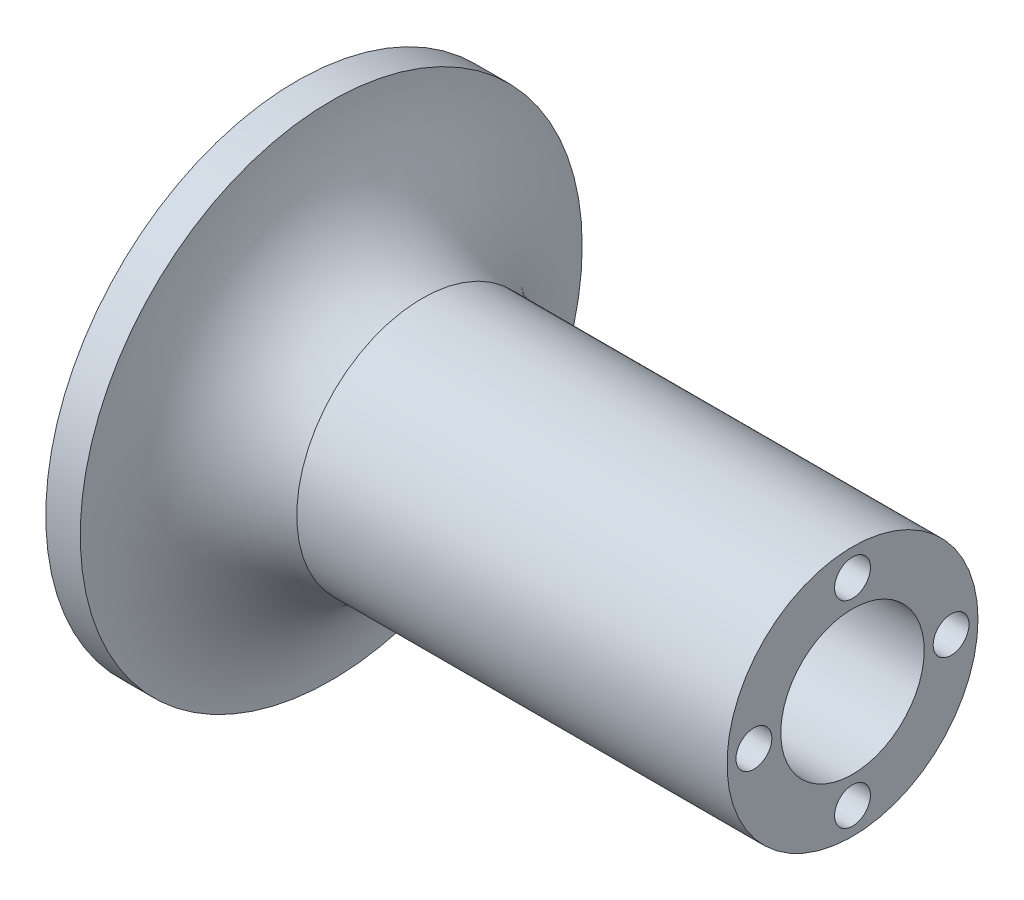
from build123d import *

# Parameters (mm, degrees)
ESBO_O8_R             = 20
CORTE_EXTRUS_O1_DEPTH = 140
ESBO_O9_R             = 5
CORTE_EXTRUS_O2_DEPTH = 20


with BuildPart() as part:
    # Esboço1 → Revolução1 (revolve)
    with BuildSketch(Plane.XY):
        with BuildLine():
            Line((-67.020117474, 0), (-94.010110831, 0))
            Line((-94.010110831, 0), (-94.010110831, 70))
            Line((-94.010110831, 70), (-84.391943284, 70))
            ThreePointArc((-84.391943284, 70), (-77.378586892, 48.382660787), (-59.010110831, 35))
            Line((-59.010110831, 35), (60.989889169, 35))
            Line((60.989889169, 35), (60.989889169, 0))
            Line((60.989889169, 0), (-67.020117474, 0))
        make_face()
    revolve(axis=Axis((-67.020117474, 0, 0), (-1, 0, 0)))

    # Esboço8 → Corte-extrusão1 (cut)
    with BuildSketch(Plane(origin=(60.989889169, 0, 0), x_dir=(0, 0, -1), z_dir=(1, 0, 0))):
        Circle(ESBO_O8_R)
    extrude(amount=-CORTE_EXTRUS_O1_DEPTH, mode=Mode.SUBTRACT)

    # Esboço9 → Corte-extrusão2 (cut)
    with BuildSketch(Plane(origin=(60.989889169, 0, 0), x_dir=(0, 0, -1), z_dir=(1, 0, 0))):
        with Locations((0, 27.5)):
            Circle(ESBO_O9_R)
        with Locations((27.5, 0)):
            Circle(ESBO_O9_R)
        with Locations((-27.5, 0)):
            Circle(ESBO_O9_R)
        with Locations((0, -27.5)):
            Circle(ESBO_O9_R)
    extrude(amount=-CORTE_EXTRUS_O2_DEPTH, mode=Mode.SUBTRACT)


solid = part.part
